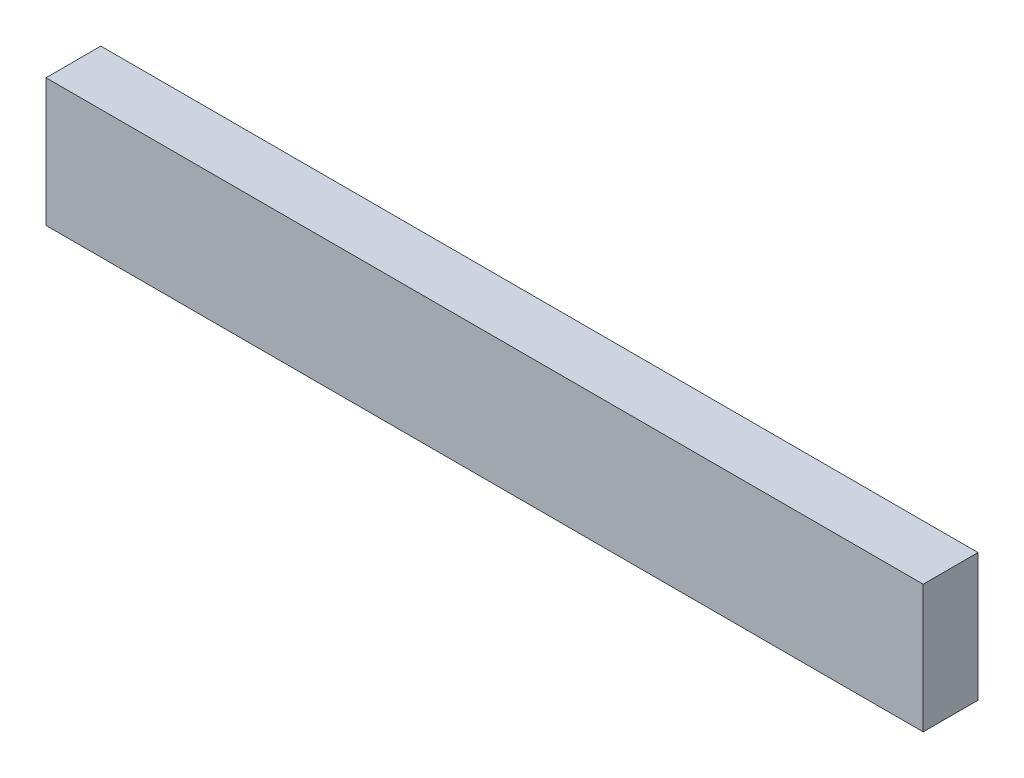
from build123d import *

# Parameters (mm, degrees)
SKETCH1_W           = 38.1
SKETCH1_H           = 88.9
BOSS_EXTRUDE1_DEPTH = 609.6


with BuildPart() as part:
    # Sketch1 → Boss-Extrude1 (new body)
    with BuildSketch(Plane(origin=(0, 0, 0), x_dir=(0, 0, -1), z_dir=(1, 0, 0))):
        Rectangle(SKETCH1_W, SKETCH1_H)
    extrude(amount=BOSS_EXTRUDE1_DEPTH)


solid = part.part
